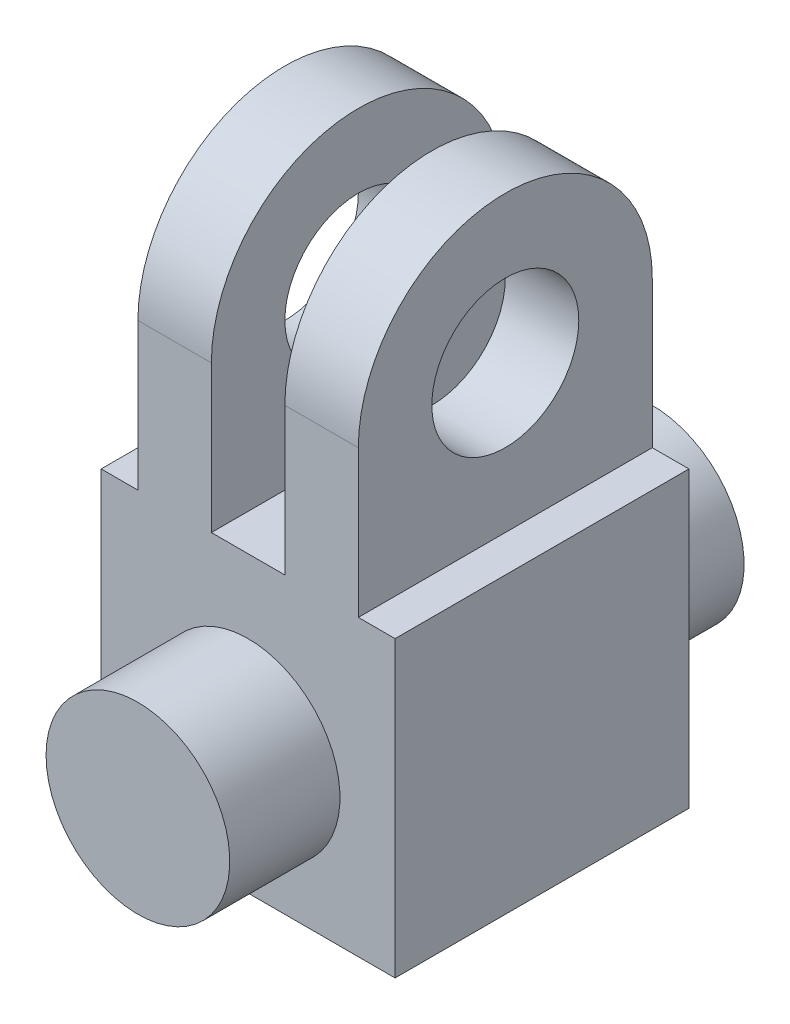
from build123d import *

# Parameters (mm, degrees)
CROQUIS1_W                   = 80
CROQUIS1_H                   = 80
SALIENTE_EXTRUIR1_DEPTH      = 160
CROQUIS2_W                   = 10
CROQUIS2_H                   = 80
CORTAR_EXTRUIR1_DEPTH        = 80
CROQUIS3_W                   = 20
CROQUIS3_H                   = 80
CORTAR_EXTRUIR2_DEPTH        = 80
CROQUIS4_R                   = 20
CORTAR_EXTRUIR3_DEPTH        = 80
CROQUIS5_R                   = 25
SALIENTE_EXTRUIR2_DEPTH      = 30
SALIENTE_EXTRUIR2_DEPTH_BACK = 110


with BuildPart() as part:
    # Croquis1 → Saliente-Extruir1 (new body)
    with BuildSketch(Plane(origin=(0, 0, 0), x_dir=(1, 0, 0), z_dir=(0, 1, 0))):
        with Locations((40, -40)):
            Rectangle(CROQUIS1_W, CROQUIS1_H)
    extrude(amount=SALIENTE_EXTRUIR1_DEPTH)

    # Croquis2 → Cortar-Extruir1 (cut)
    with BuildSketch(Plane(origin=(0, 160, 0), x_dir=(1, 0, 0), z_dir=(0, 1, 0))):
        with Locations((5, -40)):
            Rectangle(CROQUIS2_W, CROQUIS2_H)
        with Locations((75, -40)):
            Rectangle(CROQUIS2_W, CROQUIS2_H)
    extrude(amount=-CORTAR_EXTRUIR1_DEPTH, mode=Mode.SUBTRACT)

    # Croquis3 → Cortar-Extruir2 (cut)
    with BuildSketch(Plane(origin=(0, 160, 0), x_dir=(1, 0, 0), z_dir=(0, 1, 0))):
        with Locations((40, -40)):
            Rectangle(CROQUIS3_W, CROQUIS3_H)
    extrude(amount=-CORTAR_EXTRUIR2_DEPTH, mode=Mode.SUBTRACT)

    # Croquis4 → Cortar-Extruir3 (cut)
    with BuildSketch(Plane(origin=(70, 0, 0), x_dir=(0, 0, -1), z_dir=(1, 0, 0))):
        with BuildLine():
            Line((-80, 160), (-80, 120))
            ThreePointArc((-80, 120), (-68.284271247, 148.284271247), (-40, 160))
            Line((-40, 160), (-80, 160))
        make_face()
        with BuildLine():
            Line((0, 160), (-40, 160))
            ThreePointArc((-40, 160), (-11.715728753, 148.284271247), (0, 120))
            Line((0, 120), (0, 160))
        make_face()
        with Locations((-40, 120)):
            Circle(CROQUIS4_R)
    extrude(amount=-CORTAR_EXTRUIR3_DEPTH, mode=Mode.SUBTRACT)

    # Croquis5 → Saliente-Extruir2 (add, two sides)
    with BuildSketch(Plane(origin=(0, 0, 0), x_dir=(-1, 0, 0), z_dir=(0, 0, -1))) as saliente_extruir2_sk:
        with Locations((-40, 35)):
            Circle(CROQUIS5_R)
    extrude(amount=SALIENTE_EXTRUIR2_DEPTH)
    extrude(saliente_extruir2_sk.sketch, amount=-SALIENTE_EXTRUIR2_DEPTH_BACK)


solid = part.part
